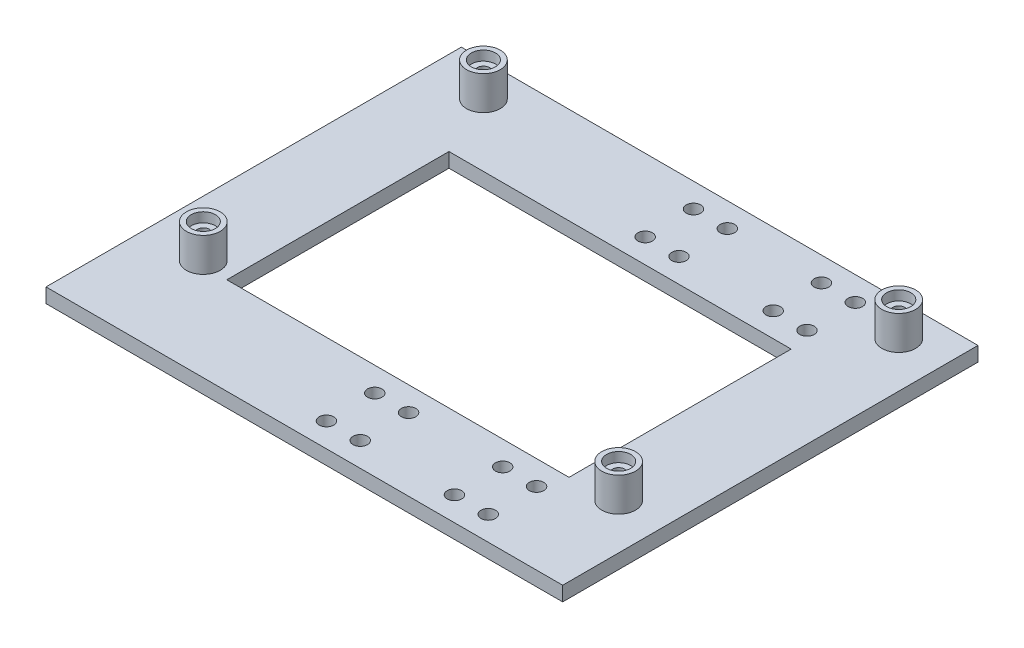
from build123d import *

# Parameters (mm, degrees)
SKETCH1_W             = 106.985396655
SKETCH1_H             = 86
SKETCH1_R             = 3.5
SKETCH1_R_2           = 1.5
BOSS_EXTRUDE1_DEPTH   = 3
SKETCH3_R             = 3.5
BOSS_EXTRUDE2_DEPTH   = 7
BOSS_EXTRUDE2_2_DEPTH = 7
BOSS_EXTRUDE2_3_DEPTH = 7
BOSS_EXTRUDE2_4_DEPTH = 7
SKETCH4_R             = 3.5
BOSS_EXTRUDE3_DEPTH   = 3
SKETCH5_R             = 1.25
CUT_EXTRUDE1_DEPTH    = 7
SKETCH6_R             = 2.5
CUT_EXTRUDE2_DEPTH    = 2


with BuildPart() as part:
    # Sketch1 → Boss-Extrude1 (new body)
    with BuildSketch(Plane(origin=(0, 0, 0), x_dir=(1, 0, 0), z_dir=(0, 1, 0))):
        with Locations((-33.080324924, 0)):
            Rectangle(SKETCH1_W, SKETCH1_H)
        with Locations((11, 36)):
            Circle(SKETCH1_R, mode=Mode.SUBTRACT)
        with Locations((-7, 38)):
            Circle(SKETCH1_R_2, mode=Mode.SUBTRACT)
        with Locations((-26.5, 38)):
            Circle(SKETCH1_R_2, mode=Mode.SUBTRACT)
        with Locations((-75, -22)):
            Circle(SKETCH1_R, mode=Mode.SUBTRACT)
        with Locations((-33.5, -38)):
            Circle(SKETCH1_R_2, mode=Mode.SUBTRACT)
        with Locations((-33.5, -28)):
            Circle(SKETCH1_R_2, mode=Mode.SUBTRACT)
        with Locations((-26.5, -38)):
            Circle(SKETCH1_R_2, mode=Mode.SUBTRACT)
        with Locations((-26.5, -28)):
            Circle(SKETCH1_R_2, mode=Mode.SUBTRACT)
        with Locations((-7, -38)):
            Circle(SKETCH1_R_2, mode=Mode.SUBTRACT)
        with Locations((0, -38)):
            Circle(SKETCH1_R_2, mode=Mode.SUBTRACT)
        with Locations((-7, -28)):
            Circle(SKETCH1_R_2, mode=Mode.SUBTRACT)
        with Locations((0, -28)):
            Circle(SKETCH1_R_2, mode=Mode.SUBTRACT)
        with Locations((11, -22)):
            Circle(SKETCH1_R, mode=Mode.SUBTRACT)
        Polygon((1.724967874, 23), (1.724967874, -22), (1.724967874, -23), (-69.131444758, -23), (-69.131444758, 23), align=None, mode=Mode.SUBTRACT)
        with Locations((-75, 36)):
            Circle(SKETCH1_R, mode=Mode.SUBTRACT)
        with Locations((-33.5, 28)):
            Circle(SKETCH1_R_2, mode=Mode.SUBTRACT)
        with Locations((-33.5, 38)):
            Circle(SKETCH1_R_2, mode=Mode.SUBTRACT)
        with Locations((-26.5, 28)):
            Circle(SKETCH1_R_2, mode=Mode.SUBTRACT)
        with Locations((-7, 28)):
            Circle(SKETCH1_R_2, mode=Mode.SUBTRACT)
        with Locations((0, 28)):
            Circle(SKETCH1_R_2, mode=Mode.SUBTRACT)
        with Locations((0, 38)):
            Circle(SKETCH1_R_2, mode=Mode.SUBTRACT)
    extrude(amount=BOSS_EXTRUDE1_DEPTH)



with BuildPart() as body_2:
    # Sketch3 → Boss-Extrude2 (new body)
    with BuildSketch(Plane(origin=(0, 3, 0), x_dir=(1, 0, 0), z_dir=(0, 1, 0))):
        with Locations((-75, -22)):
            Circle(SKETCH3_R)
    extrude(amount=BOSS_EXTRUDE2_DEPTH)


with BuildPart() as body_3:
    # Sketch3 → Boss-Extrude2 2 (new body)
    with BuildSketch(Plane(origin=(0, 3, 0), x_dir=(1, 0, 0), z_dir=(0, 1, 0))):
        with Locations((11, -22)):
            Circle(SKETCH3_R)
    extrude(amount=BOSS_EXTRUDE2_2_DEPTH)


with BuildPart() as body_4:
    # Sketch3 → Boss-Extrude2 3 (new body)
    with BuildSketch(Plane(origin=(0, 3, 0), x_dir=(1, 0, 0), z_dir=(0, 1, 0))):
        with Locations((11, 36)):
            Circle(SKETCH3_R)
    extrude(amount=BOSS_EXTRUDE2_3_DEPTH)


with BuildPart() as body_5:
    # Sketch3 → Boss-Extrude2 4 (new body)
    with BuildSketch(Plane(origin=(0, 3, 0), x_dir=(1, 0, 0), z_dir=(0, 1, 0))):
        with Locations((-75, 36)):
            Circle(SKETCH3_R)
    extrude(amount=BOSS_EXTRUDE2_4_DEPTH)


with BuildPart() as part_1:
    add(part.part)

    add(body_2.part)  # Boss-Extrude3 merges body 2

    add(body_3.part)  # Boss-Extrude3 merges body 3

    add(body_4.part)  # Boss-Extrude3 merges body 4

    add(body_5.part)  # Boss-Extrude3 merges body 5
    # Sketch4 → Boss-Extrude3 (add)
    with BuildSketch(Plane.XZ.offset(-3)):
        with Locations((-75, -36)):
            Circle(SKETCH4_R)
        with Locations((11, -36)):
            Circle(SKETCH4_R)
        with Locations((11, 22)):
            Circle(SKETCH4_R)
        with Locations((-75, 22)):
            Circle(SKETCH4_R)
    extrude(amount=BOSS_EXTRUDE3_DEPTH)

    # Sketch5 → Cut-Extrude1 (cut)
    with BuildSketch(Plane(origin=(0, 10, 0), x_dir=(1, 0, 0), z_dir=(0, 1, 0))):
        with Locations((11, 36)):
            Circle(SKETCH5_R)
        with Locations((11, -22)):
            Circle(SKETCH5_R)
        with Locations((-75, -22)):
            Circle(SKETCH5_R)
        with Locations((-75, 36)):
            Circle(SKETCH5_R)
    extrude(amount=-CUT_EXTRUDE1_DEPTH, mode=Mode.SUBTRACT)

    # Sketch6 → Cut-Extrude2 (cut)
    with BuildSketch(Plane(origin=(0, 10, 0), x_dir=(1, 0, 0), z_dir=(0, 1, 0))):
        with Locations((-75, 36)):
            Circle(SKETCH6_R)
        with Locations((11, 36)):
            Circle(SKETCH6_R)
        with Locations((-75, -22)):
            Circle(SKETCH6_R)
        with Locations((11, -22)):
            Circle(SKETCH6_R)
    extrude(amount=-CUT_EXTRUDE2_DEPTH, mode=Mode.SUBTRACT)


solid = part_1.part
